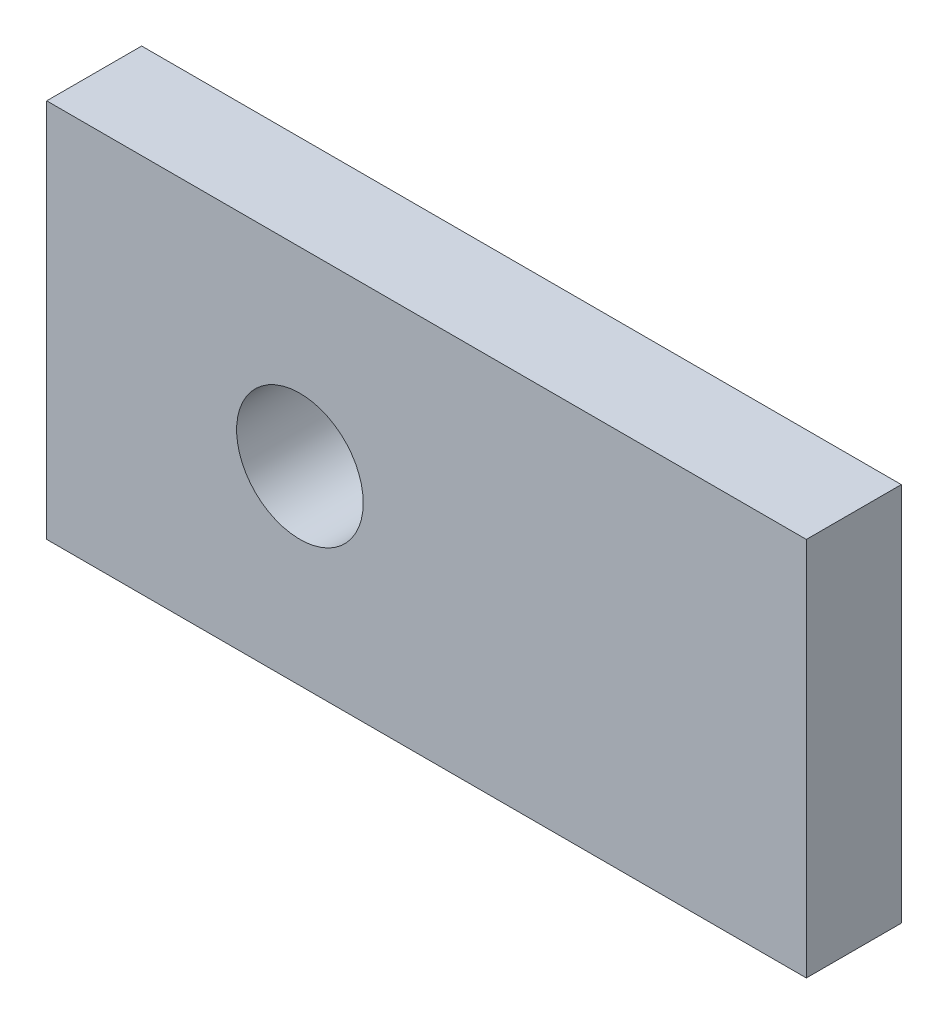
from build123d import *

# Parameters (mm, degrees)
PLAT_W                      = 60
PLAT_H                      = 15
EL_MENT_M_CANO_SOUD_1_DEPTH = 120
ESQUISSE2_R                 = 10
ENL_V_MAT_EXTRU_1_DEPTH     = 20


with BuildPart() as part:
    # plat → Elément mécano-soudé1 (new body)
    with BuildSketch(Plane.YZ.offset(-60)):
        Rectangle(PLAT_W, PLAT_H)
    extrude(amount=EL_MENT_M_CANO_SOUD_1_DEPTH)

    # Esquisse2 → Enlèv. mat.-Extru.1 (cut)
    with BuildSketch(Plane.XY.offset(7.5)):
        with Locations((-20, 0)):
            Circle(ESQUISSE2_R)
    extrude(amount=-ENL_V_MAT_EXTRU_1_DEPTH, mode=Mode.SUBTRACT)


solid = part.part
